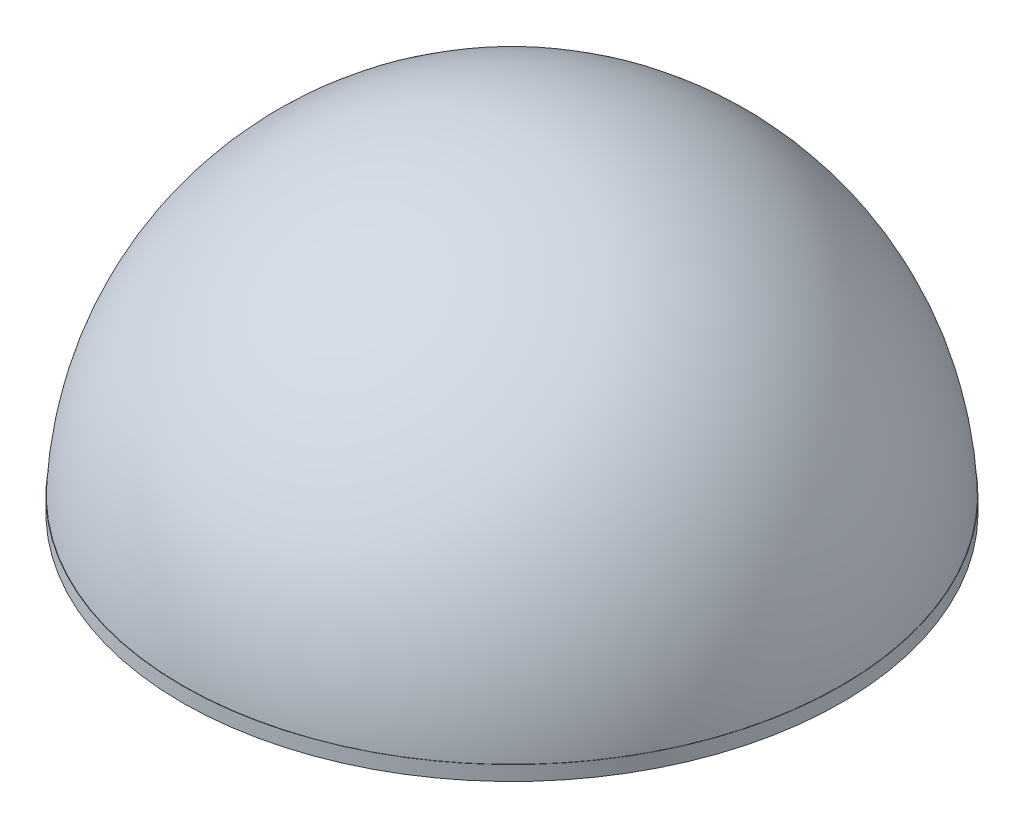
from build123d import *

# Parameters (mm, degrees)
SHELL1_T            = -2
SKETCH3_W           = 10
SKETCH3_H           = 30
FILLET1_R           = 1
SKETCH2_R           = 45
BOSS_EXTRUDE2_DEPTH = 2


with BuildPart() as part:
    # Sketch1 → Revolve1 (revolve)
    with BuildSketch(Plane.XY):
        with BuildLine():
            Line((0, 45), (0, 0))
            Line((0, 0), (45, 0))
            ThreePointArc((45, 0), (31.819805153, 31.819805153), (0, 45))
        make_face()
    revolve(axis=Axis((0, 45, 0), (0, -1, 0)))

    # Shell1
    shell1_openings = [part.faces().sort_by_distance(p)[0] for p in [
        (0, 0, 45),
    ]]
    offset(amount=SHELL1_T, openings=shell1_openings, kind=Kind.INTERSECTION)



with BuildPart() as body_2:
    # Sketch3 → Revolve2 (revolve)
    with BuildSketch(Plane.XY):
        with Locations((-5, 15)):
            Rectangle(SKETCH3_W, SKETCH3_H)
    revolve(axis=Axis((0, 30, 0), (0, -1, 0)))

    # Fillet1
    fillet1_edges = [body_2.edges().sort_by_distance(p)[0] for p in [
        (10, 30, 0),
    ]]
    fillet(fillet1_edges, radius=FILLET1_R)


with BuildPart() as part_1:
    add(part.part)

    add(body_2.part)  # Boss-Extrude2 merges body 2
    # Sketch2 → Boss-Extrude2 (add)
    with BuildSketch(Plane(origin=(0, 0, 0), x_dir=(1, 0, 0), z_dir=(0, 1, 0))):
        Circle(SKETCH2_R)
    extrude(amount=BOSS_EXTRUDE2_DEPTH)


solid = part_1.part
